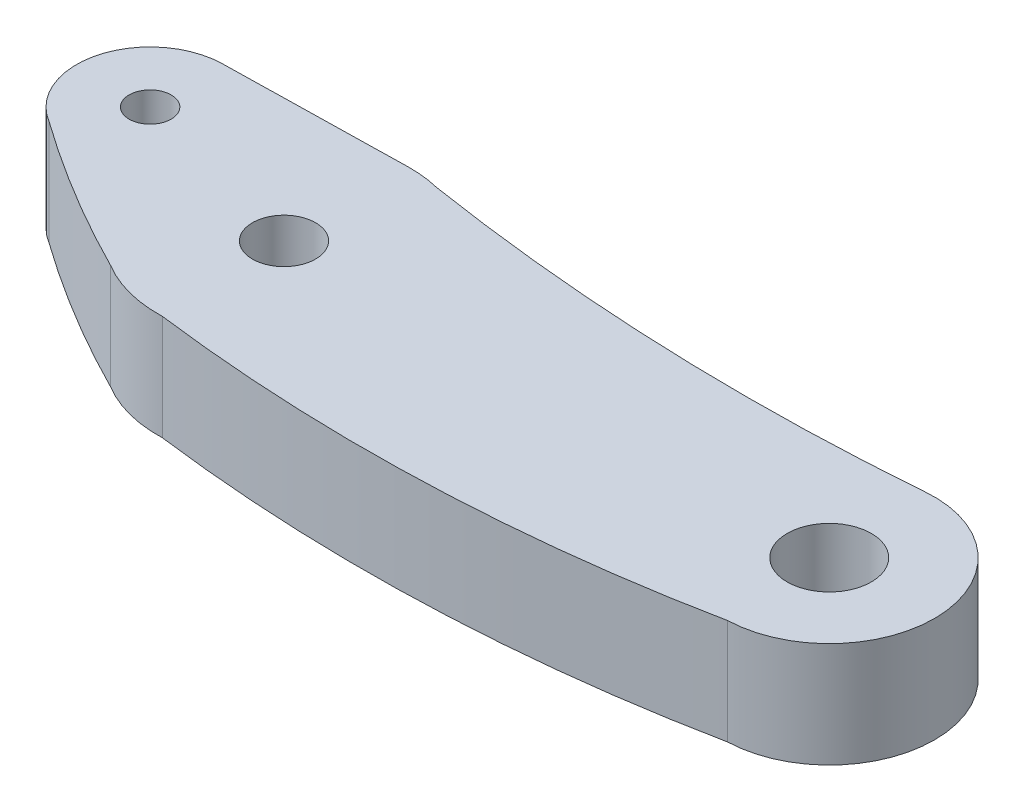
from build123d import *

# Parameters (mm, degrees)
SKETCH1_R           = 1.5
SKETCH1_R_2         = 2
SKETCH1_R_3         = 1
BOSS_EXTRUDE1_DEPTH = 5


with BuildPart() as part:
    # Sketch1 → Boss-Extrude1 (new body)
    with BuildSketch(Plane(origin=(0, 0, 0), x_dir=(1, 0, 0), z_dir=(0, 1, 0))):
        with BuildLine():
            Line((-8.762210389, 5.828693601), (-0.11807649, 5.998838049))
            ThreePointArc((-0.11807649, 5.998838049), (0.662554919, 5.963306212), (1.431947779, 5.82662214))
            ThreePointArc((1.431947779, 5.82662214), (13.458528139, 4.649327756), (25.539939967, 4.902597239))
            ThreePointArc((25.539939967, 4.902597239), (30.995866152, 0.235754194), (26.175572284, -5.085084233))
            ThreePointArc((26.175572284, -5.085084233), (13.230242543, -6.601805731), (0.210435347, -5.996308612))
            ThreePointArc((0.210435347, -5.996308612), (-1.508245613, -5.807339767), (-3.101676264, -5.136107899))
            ThreePointArc((-3.101676264, -5.136107899), (-6.887532568, -3.042769433), (-10.502643591, -0.666691535))
            ThreePointArc((-10.502643591, -0.666691535), (-12.074072829, 3.235238064), (-8.762210389, 5.828693601))
        make_face()
        Circle(SKETCH1_R, mode=Mode.SUBTRACT)
        with Locations((26, -0.082190865)):
            Circle(SKETCH1_R_2, mode=Mode.SUBTRACT)
        with Locations((-8.693332437, 2.329371406)):
            Circle(SKETCH1_R_3, mode=Mode.SUBTRACT)
    extrude(amount=BOSS_EXTRUDE1_DEPTH)


solid = part.part
